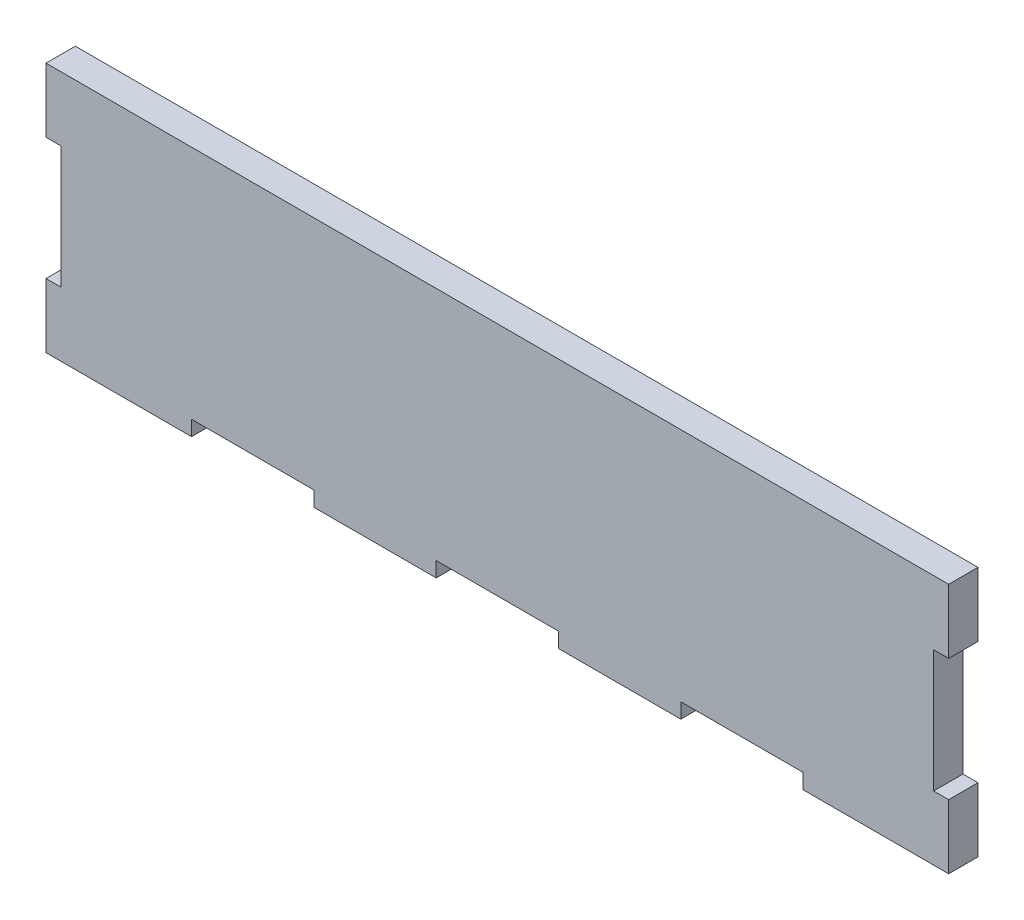
from build123d import *

# Parameters (mm, degrees)
SALIENTE_EXTRUIR1_DEPTH = 5.85


with BuildPart() as part:
    # Model → Saliente-Extruir1 (new body)
    with BuildSketch(Plane.XY):
        Polygon((0, 103), (0, 90.195), (3, 90.195), (3, 65.805), (0, 65.805), (0, 53), (29.025, 53), (29.025, 56), (53.415, 56), (53.415, 53), (77.805, 53), (77.805, 56), (102.195, 56), (102.195, 53), (126.585, 53), (126.585, 56), (150.975, 56), (150.975, 53), (175.365, 53), (180, 53), (180, 65.805), (177, 65.805), (177, 90.195), (180, 90.195), (180, 103), align=None)
    extrude(amount=SALIENTE_EXTRUIR1_DEPTH)


solid = part.part
